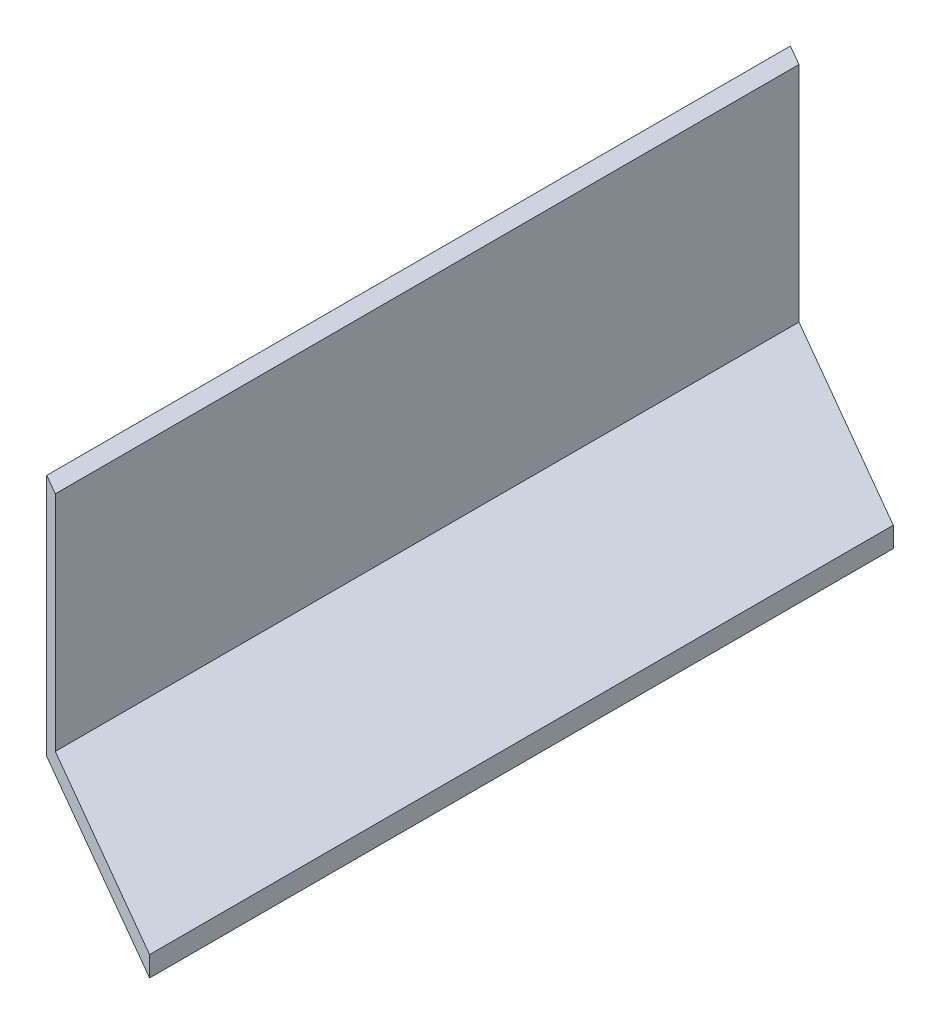
from build123d import *

# Parameters (mm, degrees)
SKETCH1_W           = 38.1
SKETCH1_H           = 38.1
BOSS_EXTRUDE1_DEPTH = 138.43
SKETCH2_W           = 34.925
SKETCH2_H           = 34.925
CUT_EXTRUDE1_DEPTH  = 139.43
CUT_EXTRUDE2_DEPTH  = 38.1


with BuildPart() as part:
    # Sketch1 → Boss-Extrude1 (new body)
    with BuildSketch(Plane.XY):
        with Locations((19.05, 19.05)):
            Rectangle(SKETCH1_W, SKETCH1_H)
    extrude(amount=BOSS_EXTRUDE1_DEPTH)

    # Sketch2 → Cut-Extrude1 (cut, through all)
    with BuildSketch(Plane.XY.offset(138.43)):
        with Locations((20.6375, 20.6375)):
            Rectangle(SKETCH2_W, SKETCH2_H)
    extrude(amount=-CUT_EXTRUDE1_DEPTH, mode=Mode.SUBTRACT)

    # Sketch3 → Cut-Extrude2 (cut)
    with BuildSketch(Plane(origin=(0, 0, 0), x_dir=(-1, 0, 0), z_dir=(0, -1, 0))):
        Polygon((0, 0), (-38.1, 0), (-38.1, -21.997045256), align=None)
        Polygon((0, -138.43), (-38.1, -138.43), (0, -116.432954744), align=None)
    extrude(amount=-CUT_EXTRUDE2_DEPTH, mode=Mode.SUBTRACT)


solid = part.part
